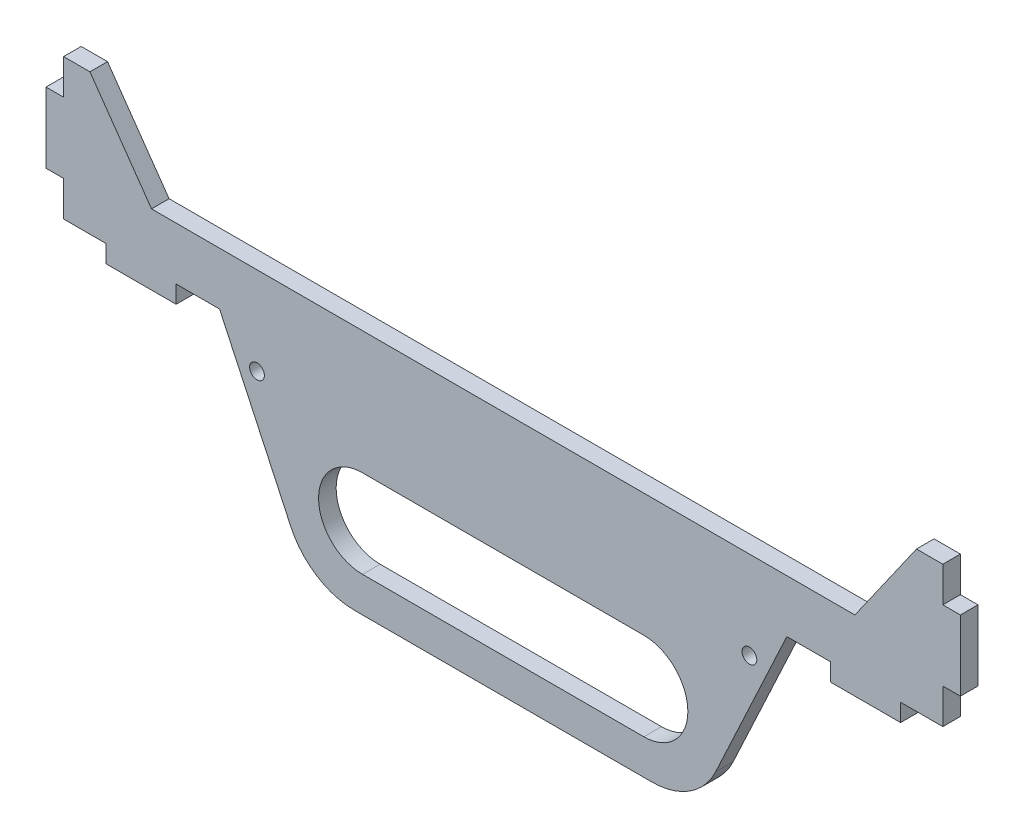
from build123d import *

# Parameters (mm, degrees)
BOSS_EXTRUDE1_DEPTH = 5
FILLET1_R           = 20
SKETCH3_R           = 2.1
CUT_EXTRUDE1_DEPTH  = 5


with BuildPart() as part:
    # Sketch1 → Boss-Extrude1 (new body)
    with BuildSketch(Plane.XY):
        Polygon((0, 0), (7.494811542, 0), (24.999999999, -25), (224.999999999, -25), (242.505188456, 0), (249.999999998, 0), (249.999999998, -10), (254.999999998, -10), (254.999999998, -30), (249.999999998, -30), (249.999999998, -40), (237.999999998, -40), (237.999999998, -45), (217.999999998, -45), (217.999999998, -40), (205.646921198, -40), (179.999999999, -95), (69.999999999, -95), (44.353078801, -40), (32, -40), (32, -45), (12, -45), (12, -40), (0, -40), (0, -30), (-5, -30), (-5, -10), (0, -10), align=None)
        with BuildLine():
            Line((84.999999999, -60), (164.999999999, -60))
            ThreePointArc((164.999999999, -60), (177.499999999, -72.5), (164.999999999, -85))
            Line((164.999999999, -85), (84.999999999, -85))
            ThreePointArc((84.999999999, -85), (72.499999999, -72.5), (84.999999999, -60))
        make_face(mode=Mode.SUBTRACT)
    extrude(amount=BOSS_EXTRUDE1_DEPTH)

    # Fillet1
    fillet1_edges = [part.edges().sort_by_distance(p)[0] for p in [
        (179.999999999, -95, 2.5),
        (69.999999999, -95, 2.5),
    ]]
    fillet(fillet1_edges, radius=FILLET1_R)

    # Sketch3 → Cut-Extrude1 (cut)
    with BuildSketch(Plane.XY.offset(5)):
        with Locations((55, -50)):
            Circle(SKETCH3_R)
    cut_extrude1 = extrude(amount=-CUT_EXTRUDE1_DEPTH, mode=Mode.SUBTRACT)

    # Mirror1: Cut-Extrude1 across plane
    add(cut_extrude1.mirror(Plane.ZY.offset(-124.999999999)), mode=Mode.SUBTRACT)


solid = part.part
